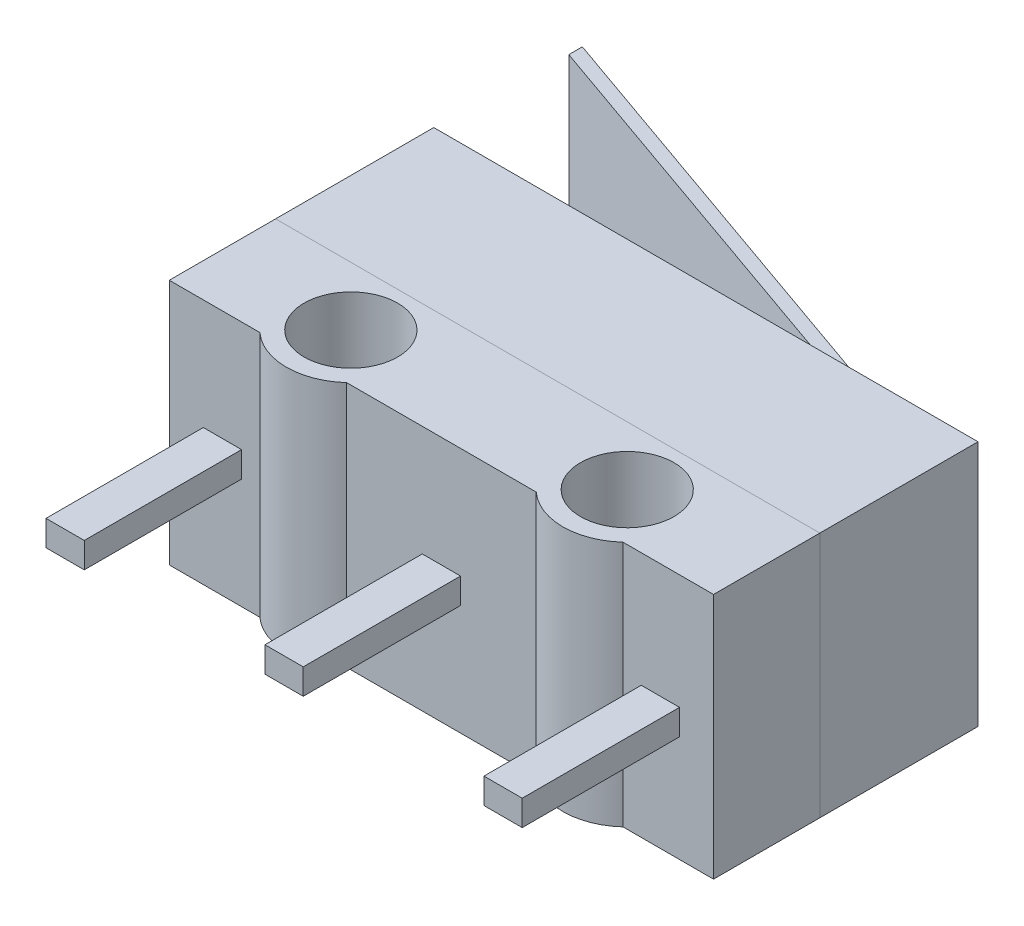
from build123d import *

# Parameters (mm, degrees)
SKETCH2_W            = 12.8
SKETCH2_H            = 5.8
BOSS_EXTRUDE1_DEPTH  = 6.22
M2_CLEARANCE_HOLE1_D = 2.2
BOSS_EXTRUDE2_DEPTH  = 5.8
SKETCH17_W           = 0.9
SKETCH17_H           = 0.6
BOSS_EXTRUDE3_DEPTH  = 3.7
BOSS_EXTRUDE5_DEPTH  = 3.1


with BuildPart() as part:
    # Sketch2 → Boss-Extrude1 (new body)
    with BuildSketch(Plane.XY):
        with Locations((-6.4, 2.9)):
            Rectangle(SKETCH2_W, SKETCH2_H)
    extrude(amount=BOSS_EXTRUDE1_DEPTH)

    # M2 Clearance Hole1 (through all)
    with Locations(Plane(origin=(0, 0, 0), x_dir=(-1, 0, 0), z_dir=(0, -1, 0))):
        with Locations((9.65, -5.1), (3.15, -5.1)):
            Hole(M2_CLEARANCE_HOLE1_D / 2)

    # Sketch16 → Boss-Extrude2 (add, through all)
    with BuildSketch(Plane.XZ):
        with BuildLine():
            Line((-10.670208312, 6.22), (-8.629791688, 6.22))
            ThreePointArc((-8.629791688, 6.22), (-9.65, 6.615), (-10.670208312, 6.22))
        make_face()
        with BuildLine():
            Line((-4.170208312, 6.22), (-2.129791688, 6.22))
            ThreePointArc((-2.129791688, 6.22), (-3.15, 6.615), (-4.170208312, 6.22))
        make_face()
    extrude(amount=-BOSS_EXTRUDE2_DEPTH)

    # Sketch17 → Boss-Extrude3 (add)
    with BuildSketch(Plane.XY.offset(6.22)):
        with Locations((-6.4, 2.9)):
            Rectangle(SKETCH17_W, SKETCH17_H)
        with Locations((-11.55, 2.9)):
            Rectangle(SKETCH17_W, SKETCH17_H)
        with Locations((-1.25, 2.8)):
            Rectangle(SKETCH17_W, SKETCH17_H)
    extrude(amount=BOSS_EXTRUDE3_DEPTH)

    # Sketch19 → Boss-Extrude5 (add)
    with BuildSketch(Plane(origin=(0, 1.35, 0), x_dir=(1, 0, 0), z_dir=(0, 1, 0))):
        Polygon((-4.3, 1), (-1.452673729, 0), (-1, 0), (-0.547326271, 0), (-0.950295326, 0.141525423), (-14.047326271, 4.741290149), (-14.047326271, 4.423326076), align=None)
    extrude(amount=BOSS_EXTRUDE5_DEPTH)


solid = part.part
